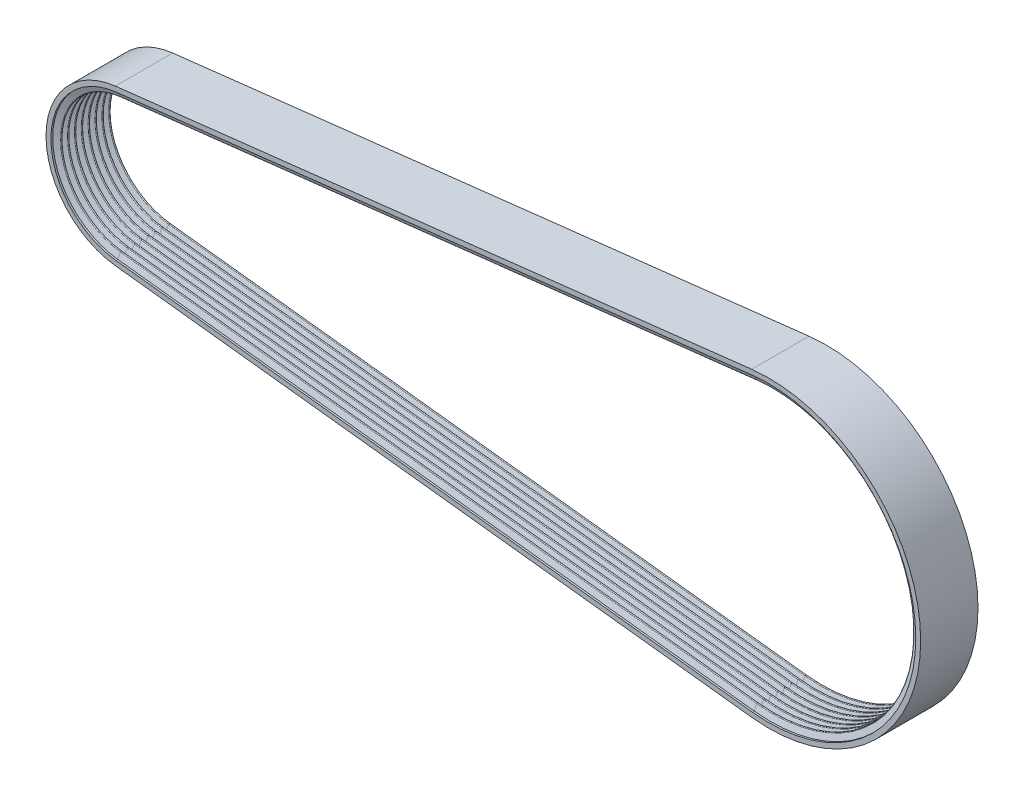
from build123d import *


with BuildPart() as part:
    # Sweep1: sweep along a path in Sketch1
    with BuildLine(Plane.XY) as sweep1_path:
        Line((-4.338090178, 37.852225478), (325.943419645, 75.704450955))
        ThreePointArc((325.943419645, 75.704450955), (410.8196, 0), (325.943419645, -75.704450955))
        Line((325.943419645, -75.704450955), (-4.338090178, -37.852225478))
        ThreePointArc((-4.338090178, -37.852225478), (-38.1, 0), (-4.338090178, 37.852225478))
    # Sketch2 → Sweep1 (sweep)
    with BuildSketch(Plane(origin=(-4.338090178, 37.852225478, 0), x_dir=(0, 0, -1), z_dir=(0.993496731696836, 0.11386063458327017, 0))):
        with BuildLine():
            Line((0, 2.54), (14.879437111, 2.54))
            Line((14.879437111, 2.54), (14.879437111, 0))
            Line((14.879437111, 0), (13.926937111, 0))
            Line((13.926937111, 0), (12.857362889, -2.938631026))
            ThreePointArc((12.857362889, -2.938631026), (12.49934, -3.189321351), (12.141317111, -2.938631026))
            Line((12.141317111, -2.938631026), (11.071742889, 0))
            ThreePointArc((11.071742889, 0), (10.71372, 0.250690325), (10.355697111, 0))
            Line((10.355697111, 0), (9.286122889, -2.938631026))
            ThreePointArc((9.286122889, -2.938631026), (8.9281, -3.189321351), (8.570077111, -2.938631026))
            Line((8.570077111, -2.938631026), (7.500502889, 0))
            ThreePointArc((7.500502889, 0), (7.14248, 0.250690325), (6.784457111, 0))
            Line((6.784457111, 0), (5.714882889, -2.938631026))
            ThreePointArc((5.714882889, -2.938631026), (5.35686, -3.189321351), (4.998837111, -2.938631026))
            Line((4.998837111, -2.938631026), (3.929262889, 0))
            ThreePointArc((3.929262889, 0), (3.57124, 0.250690325), (3.213217111, 0))
            Line((3.213217111, 0), (2.143642889, -2.938631026))
            ThreePointArc((2.143642889, -2.938631026), (1.78562, -3.189321351), (1.427597111, -2.938631026))
            Line((1.427597111, -2.938631026), (0.358022889, 0))
            ThreePointArc((0.358022889, 0), (0.218532622, 0.181787254), (0, 0.250690325))
            Line((0, 0.250690325), (0, 2.54))
        make_face()
    sweep1 = sweep(path=sweep1_path.line)

    # Mirror1: Sweep1 across Front Plane
    add(sweep1.mirror(Plane.XY))


solid = part.part
